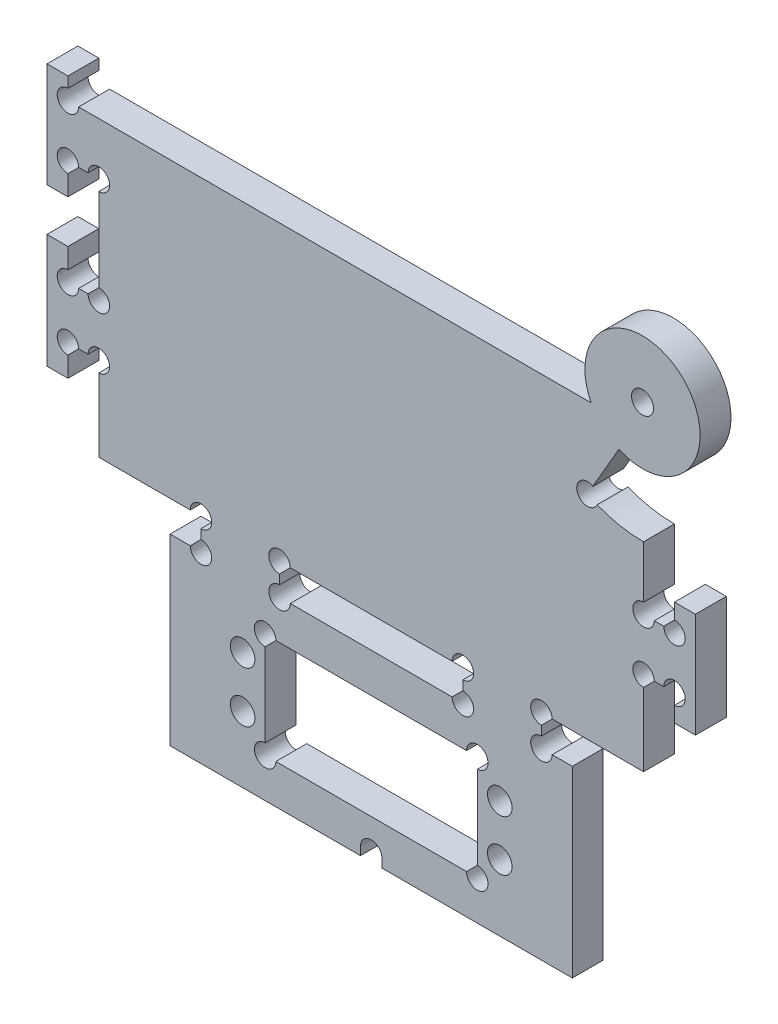
from build123d import *

# Parameters (mm, degrees)
SKETCH2_W           = 104
SKETCH2_H           = 66
BOSS_EXTRUDE1_DEPTH = 5.9
BOSS_EXTRUDE2_DEPTH = 5.9
SKETCH4_W           = 104
SKETCH4_H           = 10
CUT_EXTRUDE1_DEPTH  = 8
BOSS_EXTRUDE4_DEPTH = 5.9
CUT_EXTRUDE2_DEPTH  = 8
SKETCH9_R           = 2.1
CUT_EXTRUDE3_DEPTH  = 6.9
CUT_EXTRUDE4_REACH  = 7.9
SKETCH10_R          = 2.35
SKETCH10_W          = 40.5
SKETCH10_H          = 20
CUT_EXTRUDE5_REACH  = 7.9
SKETCH11_R          = 2.05
CUT_EXTRUDE6_REACH  = 7.9


with BuildPart() as part:
    # Sketch2 → Boss-Extrude1 (new body)
    with BuildSketch(Plane.XY):
        Rectangle(SKETCH2_W, SKETCH2_H)
    extrude(amount=BOSS_EXTRUDE1_DEPTH)

    # Sketch3 → Boss-Extrude2 (add, through all)
    with BuildSketch(Plane.XY.offset(5.9)):
        Polygon((-52, -17), (-57.9, -17), (-57.9, -22.9), (-61.9, -22.9), (-61.9, -1.1), (-57.9, -1.1), (-57.9, -7), (-52, -7), align=None)
        Polygon((-52, 13), (-57.9, 13), (-57.9, 7.1), (-61.9, 7.1), (-61.9, 27.1), (-57.9, 27.1), (-57.9, 23), (-52, 23), align=None)
        Polygon((52, -7), (52, -17), (57.9, -17), (57.9, -22), (61.9, -22), (61.9, -2), (57.9, -2), (57.9, -7), align=None)
        Polygon((-32.5, -33), (-32.5, -38.9), (-38.4, -38.9), (-38.4, -73.9), (38.4, -73.9), (38.4, -38.9), (32.5, -38.9), (32.5, -33), (17.5, -33), (17.5, -38.9), (-17.5, -38.9), (-17.5, -33), align=None)
    extrude(amount=-BOSS_EXTRUDE2_DEPTH)

    # Sketch4 → Cut-Extrude1 (cut)
    with BuildSketch(Plane.XY.offset(5.9)):
        with Locations((0, 28)):
            Rectangle(SKETCH4_W, SKETCH4_H)
    extrude(amount=-CUT_EXTRUDE1_DEPTH, mode=Mode.SUBTRACT)

    # Sketch6 → Boss-Extrude4 (add)
    with BuildSketch(Plane.XY.offset(5.9)):
        with BuildLine():
            Line((52, 17), (52, 0))
            Line((52, 0), (0, 0))
            Line((0, 0), (0, 23))
            Line((0, 23), (42, 23))
            ThreePointArc((42, 23), (57.458350242, 37.430583736), (52, 17))
        make_face()
    extrude(amount=-BOSS_EXTRUDE4_DEPTH)

    # Sketch8 → Cut-Extrude2 (cut)
    with BuildSketch(Plane.XY.offset(5.9)):
        with BuildLine():
            Line((47.287664075, 17.965775092), (41.287664075, 7.573470247))
            ThreePointArc((41.287664075, 7.573470247), (46.489081435, 5.649562257), (52, 5.028320703))
            Line((52, 5.028320703), (52, 17))
            ThreePointArc((52, 17), (49.590394027, 17.222145828), (47.287664075, 17.965775092))
        make_face()
    extrude(amount=-CUT_EXTRUDE2_DEPTH, mode=Mode.SUBTRACT)

    # Sketch9 → Cut-Extrude3 (cut, through all)
    with BuildSketch(Plane.XY.offset(5.9)):
        with Locations((51.798896932, 27.998161553)):
            Circle(SKETCH9_R)
    extrude(amount=-CUT_EXTRUDE3_DEPTH, mode=Mode.SUBTRACT)

    # Sketch10 → Cut-Extrude4 (cut, up to next)
    with BuildSketch(Plane.XY.offset(5.9), mode=Mode.PRIVATE) as cut_extrude4_sk1:
        with Locations((-24.55, -51.55)):
            Circle(SKETCH10_R)
    cut_extrude4_tool1 = extrude(cut_extrude4_sk1.sketch, amount=-CUT_EXTRUDE4_REACH, mode=Mode.PRIVATE) & part.part
    add(cut_extrude4_tool1.solids().sort_by_distance((-24.55, -51.55, 5.9))[0], mode=Mode.SUBTRACT)
    # Sketch10 → Cut-Extrude4 (cut, up to next)
    with BuildSketch(Plane.XY.offset(5.9), mode=Mode.PRIVATE) as cut_extrude4_sk2:
        with Locations((-24.55, -61.25)):
            Circle(SKETCH10_R)
    cut_extrude4_tool2 = extrude(cut_extrude4_sk2.sketch, amount=-CUT_EXTRUDE4_REACH, mode=Mode.PRIVATE) & part.part
    add(cut_extrude4_tool2.solids().sort_by_distance((-24.55, -61.25, 5.9))[0], mode=Mode.SUBTRACT)
    # Sketch10 → Cut-Extrude4 (cut, up to next)
    with BuildSketch(Plane.XY.offset(5.9), mode=Mode.PRIVATE) as cut_extrude4_sk3:
        with Locations((24.55, -61.25)):
            Circle(SKETCH10_R)
    cut_extrude4_tool3 = extrude(cut_extrude4_sk3.sketch, amount=-CUT_EXTRUDE4_REACH, mode=Mode.PRIVATE) & part.part
    add(cut_extrude4_tool3.solids().sort_by_distance((24.55, -61.25, 5.9))[0], mode=Mode.SUBTRACT)
    # Sketch10 → Cut-Extrude4 (cut, up to next)
    with BuildSketch(Plane.XY.offset(5.9), mode=Mode.PRIVATE) as cut_extrude4_sk4:
        with Locations((24.55, -51.55)):
            Circle(SKETCH10_R)
    cut_extrude4_tool4 = extrude(cut_extrude4_sk4.sketch, amount=-CUT_EXTRUDE4_REACH, mode=Mode.PRIVATE) & part.part
    add(cut_extrude4_tool4.solids().sort_by_distance((24.55, -51.55, 5.9))[0], mode=Mode.SUBTRACT)
    # Sketch10 → Cut-Extrude4 (cut, up to next)
    with BuildSketch(Plane.XY.offset(5.9), mode=Mode.PRIVATE) as cut_extrude4_sk5:
        with Locations((0, -56.4)):
            Rectangle(SKETCH10_W, SKETCH10_H)
    cut_extrude4_tool5 = extrude(cut_extrude4_sk5.sketch, amount=-CUT_EXTRUDE4_REACH, mode=Mode.PRIVATE) & part.part
    add(cut_extrude4_tool5.solids().sort_by_distance((0, -56.4, 5.9))[0], mode=Mode.SUBTRACT)

    # Sketch11 → Cut-Extrude5 (cut, up to next)
    with BuildSketch(Plane.XY.offset(5.9), mode=Mode.PRIVATE) as cut_extrude5_sk1:
        with Locations((-52, 13)):
            Circle(SKETCH11_R)
    cut_extrude5_tool1 = extrude(cut_extrude5_sk1.sketch, amount=-CUT_EXTRUDE5_REACH, mode=Mode.PRIVATE) & part.part
    add(cut_extrude5_tool1.solids().sort_by_distance((-52, 13, 5.9))[0], mode=Mode.SUBTRACT)
    # Sketch11 → Cut-Extrude5 (cut, up to next)
    with BuildSketch(Plane.XY.offset(5.9), mode=Mode.PRIVATE) as cut_extrude5_sk2:
        with Locations((-52, -7)):
            Circle(SKETCH11_R)
    cut_extrude5_tool2 = extrude(cut_extrude5_sk2.sketch, amount=-CUT_EXTRUDE5_REACH, mode=Mode.PRIVATE) & part.part
    add(cut_extrude5_tool2.solids().sort_by_distance((-52, -7, 5.9))[0], mode=Mode.SUBTRACT)
    # Sketch11 → Cut-Extrude5 (cut, up to next)
    with BuildSketch(Plane.XY.offset(5.9), mode=Mode.PRIVATE) as cut_extrude5_sk3:
        with Locations((-57.9, -7)):
            Circle(SKETCH11_R)
    cut_extrude5_tool3 = extrude(cut_extrude5_sk3.sketch, amount=-CUT_EXTRUDE5_REACH, mode=Mode.PRIVATE) & part.part
    add(cut_extrude5_tool3.solids().sort_by_distance((-57.9, -7, 5.9))[0], mode=Mode.SUBTRACT)
    # Sketch11 → Cut-Extrude5 (cut, up to next)
    with BuildSketch(Plane.XY.offset(5.9), mode=Mode.PRIVATE) as cut_extrude5_sk4:
        with Locations((-57.9, 13)):
            Circle(SKETCH11_R)
    cut_extrude5_tool4 = extrude(cut_extrude5_sk4.sketch, amount=-CUT_EXTRUDE5_REACH, mode=Mode.PRIVATE) & part.part
    add(cut_extrude5_tool4.solids().sort_by_distance((-57.9, 13, 5.9))[0], mode=Mode.SUBTRACT)
    # Sketch11 → Cut-Extrude5 (cut, up to next)
    with BuildSketch(Plane.XY.offset(5.9), mode=Mode.PRIVATE) as cut_extrude5_sk5:
        with Locations((-57.9, 23)):
            Circle(SKETCH11_R)
    cut_extrude5_tool5 = extrude(cut_extrude5_sk5.sketch, amount=-CUT_EXTRUDE5_REACH, mode=Mode.PRIVATE) & part.part
    add(cut_extrude5_tool5.solids().sort_by_distance((-57.9, 23, 5.9))[0], mode=Mode.SUBTRACT)
    # Sketch11 → Cut-Extrude5 (cut, up to next)
    with BuildSketch(Plane.XY.offset(5.9), mode=Mode.PRIVATE) as cut_extrude5_sk6:
        with Locations((-52, -17)):
            Circle(SKETCH11_R)
    cut_extrude5_tool6 = extrude(cut_extrude5_sk6.sketch, amount=-CUT_EXTRUDE5_REACH, mode=Mode.PRIVATE) & part.part
    add(cut_extrude5_tool6.solids().sort_by_distance((-52, -17, 5.9))[0], mode=Mode.SUBTRACT)
    # Sketch11 → Cut-Extrude5 (cut, up to next)
    with BuildSketch(Plane.XY.offset(5.9), mode=Mode.PRIVATE) as cut_extrude5_sk7:
        with Locations((-57.9, -17)):
            Circle(SKETCH11_R)
    cut_extrude5_tool7 = extrude(cut_extrude5_sk7.sketch, amount=-CUT_EXTRUDE5_REACH, mode=Mode.PRIVATE) & part.part
    add(cut_extrude5_tool7.solids().sort_by_distance((-57.9, -17, 5.9))[0], mode=Mode.SUBTRACT)
    # Sketch11 → Cut-Extrude5 (cut, up to next)
    with BuildSketch(Plane.XY.offset(5.9), mode=Mode.PRIVATE) as cut_extrude5_sk8:
        with Locations((-32.5, -38.9)):
            Circle(SKETCH11_R)
    cut_extrude5_tool8 = extrude(cut_extrude5_sk8.sketch, amount=-CUT_EXTRUDE5_REACH, mode=Mode.PRIVATE) & part.part
    add(cut_extrude5_tool8.solids().sort_by_distance((-32.5, -38.9, 5.9))[0], mode=Mode.SUBTRACT)
    # Sketch11 → Cut-Extrude5 (cut, up to next)
    with BuildSketch(Plane.XY.offset(5.9), mode=Mode.PRIVATE) as cut_extrude5_sk9:
        with Locations((-32.5, -33)):
            Circle(SKETCH11_R)
    cut_extrude5_tool9 = extrude(cut_extrude5_sk9.sketch, amount=-CUT_EXTRUDE5_REACH, mode=Mode.PRIVATE) & part.part
    add(cut_extrude5_tool9.solids().sort_by_distance((-32.5, -33, 5.9))[0], mode=Mode.SUBTRACT)
    # Sketch11 → Cut-Extrude5 (cut, up to next)
    with BuildSketch(Plane.XY.offset(5.9), mode=Mode.PRIVATE) as cut_extrude5_sk10:
        with Locations((-17.5, -33)):
            Circle(SKETCH11_R)
    cut_extrude5_tool10 = extrude(cut_extrude5_sk10.sketch, amount=-CUT_EXTRUDE5_REACH, mode=Mode.PRIVATE) & part.part
    add(cut_extrude5_tool10.solids().sort_by_distance((-17.5, -33, 5.9))[0], mode=Mode.SUBTRACT)
    # Sketch11 → Cut-Extrude5 (cut, up to next)
    with BuildSketch(Plane.XY.offset(5.9), mode=Mode.PRIVATE) as cut_extrude5_sk11:
        with Locations((-17.5, -38.9)):
            Circle(SKETCH11_R)
    cut_extrude5_tool11 = extrude(cut_extrude5_sk11.sketch, amount=-CUT_EXTRUDE5_REACH, mode=Mode.PRIVATE) & part.part
    add(cut_extrude5_tool11.solids().sort_by_distance((-17.5, -38.9, 5.9))[0], mode=Mode.SUBTRACT)
    # Sketch11 → Cut-Extrude5 (cut, up to next)
    with BuildSketch(Plane.XY.offset(5.9), mode=Mode.PRIVATE) as cut_extrude5_sk12:
        with Locations((17.5, -33)):
            Circle(SKETCH11_R)
    cut_extrude5_tool12 = extrude(cut_extrude5_sk12.sketch, amount=-CUT_EXTRUDE5_REACH, mode=Mode.PRIVATE) & part.part
    add(cut_extrude5_tool12.solids().sort_by_distance((17.5, -33, 5.9))[0], mode=Mode.SUBTRACT)
    # Sketch11 → Cut-Extrude5 (cut, up to next)
    with BuildSketch(Plane.XY.offset(5.9), mode=Mode.PRIVATE) as cut_extrude5_sk13:
        with Locations((17.5, -38.9)):
            Circle(SKETCH11_R)
    cut_extrude5_tool13 = extrude(cut_extrude5_sk13.sketch, amount=-CUT_EXTRUDE5_REACH, mode=Mode.PRIVATE) & part.part
    add(cut_extrude5_tool13.solids().sort_by_distance((17.5, -38.9, 5.9))[0], mode=Mode.SUBTRACT)
    # Sketch11 → Cut-Extrude5 (cut, up to next)
    with BuildSketch(Plane.XY.offset(5.9), mode=Mode.PRIVATE) as cut_extrude5_sk14:
        with Locations((32.5, -33)):
            Circle(SKETCH11_R)
    cut_extrude5_tool14 = extrude(cut_extrude5_sk14.sketch, amount=-CUT_EXTRUDE5_REACH, mode=Mode.PRIVATE) & part.part
    add(cut_extrude5_tool14.solids().sort_by_distance((32.5, -33, 5.9))[0], mode=Mode.SUBTRACT)
    # Sketch11 → Cut-Extrude5 (cut, up to next)
    with BuildSketch(Plane.XY.offset(5.9), mode=Mode.PRIVATE) as cut_extrude5_sk15:
        with Locations((32.5, -38.9)):
            Circle(SKETCH11_R)
    cut_extrude5_tool15 = extrude(cut_extrude5_sk15.sketch, amount=-CUT_EXTRUDE5_REACH, mode=Mode.PRIVATE) & part.part
    add(cut_extrude5_tool15.solids().sort_by_distance((32.5, -38.9, 5.9))[0], mode=Mode.SUBTRACT)
    # Sketch11 → Cut-Extrude5 (cut, up to next)
    with BuildSketch(Plane.XY.offset(5.9), mode=Mode.PRIVATE) as cut_extrude5_sk16:
        with Locations((-20.25, -46.4)):
            Circle(SKETCH11_R)
    cut_extrude5_tool16 = extrude(cut_extrude5_sk16.sketch, amount=-CUT_EXTRUDE5_REACH, mode=Mode.PRIVATE) & part.part
    add(cut_extrude5_tool16.solids().sort_by_distance((-20.25, -46.4, 5.9))[0], mode=Mode.SUBTRACT)
    # Sketch11 → Cut-Extrude5 (cut, up to next)
    with BuildSketch(Plane.XY.offset(5.9), mode=Mode.PRIVATE) as cut_extrude5_sk17:
        with Locations((-20.25, -66.4)):
            Circle(SKETCH11_R)
    cut_extrude5_tool17 = extrude(cut_extrude5_sk17.sketch, amount=-CUT_EXTRUDE5_REACH, mode=Mode.PRIVATE) & part.part
    add(cut_extrude5_tool17.solids().sort_by_distance((-20.25, -66.4, 5.9))[0], mode=Mode.SUBTRACT)
    # Sketch11 → Cut-Extrude5 (cut, up to next)
    with BuildSketch(Plane.XY.offset(5.9), mode=Mode.PRIVATE) as cut_extrude5_sk18:
        with Locations((20.25, -66.4)):
            Circle(SKETCH11_R)
    cut_extrude5_tool18 = extrude(cut_extrude5_sk18.sketch, amount=-CUT_EXTRUDE5_REACH, mode=Mode.PRIVATE) & part.part
    add(cut_extrude5_tool18.solids().sort_by_distance((20.25, -66.4, 5.9))[0], mode=Mode.SUBTRACT)
    # Sketch11 → Cut-Extrude5 (cut, up to next)
    with BuildSketch(Plane.XY.offset(5.9), mode=Mode.PRIVATE) as cut_extrude5_sk19:
        with Locations((20.25, -46.4)):
            Circle(SKETCH11_R)
    cut_extrude5_tool19 = extrude(cut_extrude5_sk19.sketch, amount=-CUT_EXTRUDE5_REACH, mode=Mode.PRIVATE) & part.part
    add(cut_extrude5_tool19.solids().sort_by_distance((20.25, -46.4, 5.9))[0], mode=Mode.SUBTRACT)
    # Sketch11 → Cut-Extrude5 (cut, up to next)
    with BuildSketch(Plane.XY.offset(5.9), mode=Mode.PRIVATE) as cut_extrude5_sk20:
        with Locations((52, -17)):
            Circle(SKETCH11_R)
    cut_extrude5_tool20 = extrude(cut_extrude5_sk20.sketch, amount=-CUT_EXTRUDE5_REACH, mode=Mode.PRIVATE) & part.part
    add(cut_extrude5_tool20.solids().sort_by_distance((52, -17, 5.9))[0], mode=Mode.SUBTRACT)
    # Sketch11 → Cut-Extrude5 (cut, up to next)
    with BuildSketch(Plane.XY.offset(5.9), mode=Mode.PRIVATE) as cut_extrude5_sk21:
        with Locations((57.9, -17)):
            Circle(SKETCH11_R)
    cut_extrude5_tool21 = extrude(cut_extrude5_sk21.sketch, amount=-CUT_EXTRUDE5_REACH, mode=Mode.PRIVATE) & part.part
    add(cut_extrude5_tool21.solids().sort_by_distance((57.9, -17, 5.9))[0], mode=Mode.SUBTRACT)
    # Sketch11 → Cut-Extrude5 (cut, up to next)
    with BuildSketch(Plane.XY.offset(5.9), mode=Mode.PRIVATE) as cut_extrude5_sk22:
        with Locations((57.9, -7)):
            Circle(SKETCH11_R)
    cut_extrude5_tool22 = extrude(cut_extrude5_sk22.sketch, amount=-CUT_EXTRUDE5_REACH, mode=Mode.PRIVATE) & part.part
    add(cut_extrude5_tool22.solids().sort_by_distance((57.9, -7, 5.9))[0], mode=Mode.SUBTRACT)
    # Sketch11 → Cut-Extrude5 (cut, up to next)
    with BuildSketch(Plane.XY.offset(5.9), mode=Mode.PRIVATE) as cut_extrude5_sk23:
        with Locations((52, -7)):
            Circle(SKETCH11_R)
    cut_extrude5_tool23 = extrude(cut_extrude5_sk23.sketch, amount=-CUT_EXTRUDE5_REACH, mode=Mode.PRIVATE) & part.part
    add(cut_extrude5_tool23.solids().sort_by_distance((52, -7, 5.9))[0], mode=Mode.SUBTRACT)
    # Sketch11 → Cut-Extrude5 (cut, up to next)
    with BuildSketch(Plane.XY.offset(5.9), mode=Mode.PRIVATE) as cut_extrude5_sk24:
        with Locations((41.287664075, 7.573470247)):
            Circle(SKETCH11_R)
    cut_extrude5_tool24 = extrude(cut_extrude5_sk24.sketch, amount=-CUT_EXTRUDE5_REACH, mode=Mode.PRIVATE) & part.part
    add(cut_extrude5_tool24.solids().sort_by_distance((41.287664, 7.57347, 5.9))[0], mode=Mode.SUBTRACT)

    # Sketch12 → Cut-Extrude6 (cut, up to next)
    with BuildSketch(Plane.XY.offset(5.9), mode=Mode.PRIVATE) as cut_extrude6_sk1:
        with BuildLine():
            Line((-2.05, -72.3), (-2.05, -73.9))
            Line((-2.05, -73.9), (2.05, -73.9))
            Line((2.05, -73.9), (2.05, -72.3))
            ThreePointArc((2.05, -72.3), (0, -70.25), (-2.05, -72.3))
        make_face()
    cut_extrude6_tool1 = extrude(cut_extrude6_sk1.sketch, amount=-CUT_EXTRUDE6_REACH, mode=Mode.PRIVATE) & part.part
    add(cut_extrude6_tool1.solids().sort_by_distance((0, -72.262358, 5.9))[0], mode=Mode.SUBTRACT)


solid = part.part
